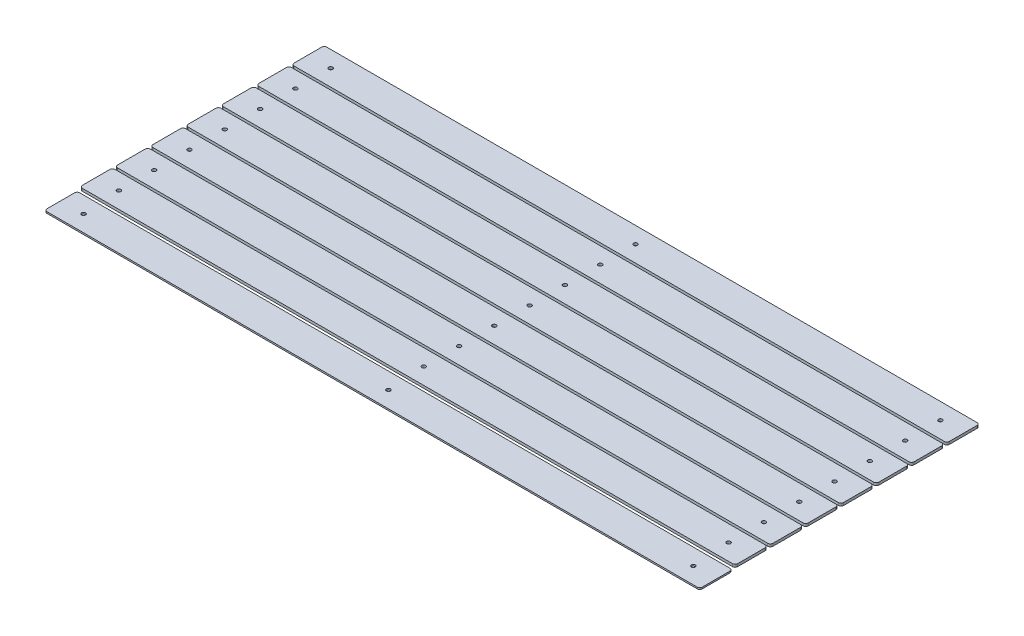
from build123d import *

# Parameters (mm, degrees)
SKETCH1_W             = 636.566333418
SKETCH1_H             = 31.75
BOSS_EXTRUDE1_DEPTH   = 1.524
SKETCH2_R             = 1.905
CUT_EXTRUDE1_DEPTH    = 2.524
FILLET1_R             = 2.54
SKETCH3_R             = 1.905
BOSS_EXTRUDE2_DEPTH   = 2.54
BOSS_EXTRUDE2_2_DEPTH = 2.54
BOSS_EXTRUDE2_3_DEPTH = 2.54
BOSS_EXTRUDE2_4_DEPTH = 2.54
BOSS_EXTRUDE2_5_DEPTH = 2.54
BOSS_EXTRUDE2_6_DEPTH = 2.54
BOSS_EXTRUDE2_7_DEPTH = 2.54


with BuildPart() as part:
    # Sketch1 → Boss-Extrude1 (new body)
    with BuildSketch(Plane(origin=(0, 0, 0), x_dir=(1, 0, 0), z_dir=(0, 1, 0))):
        Rectangle(SKETCH1_W, SKETCH1_H)
    extrude(amount=BOSS_EXTRUDE1_DEPTH)

    # Sketch2 → Cut-Extrude1 (cut, through all)
    with BuildSketch(Plane(origin=(0, 1.524, 0), x_dir=(1, 0, 0), z_dir=(0, 1, 0))):
        with Locations((-296.164, 0)):
            Circle(SKETCH2_R)
        with Locations((296.164, 0)):
            Circle(SKETCH2_R)
        Circle(SKETCH2_R)
    extrude(amount=-CUT_EXTRUDE1_DEPTH, mode=Mode.SUBTRACT)

    # Fillet1
    fillet1_edges = [part.edges().sort_by_distance(p)[0] for p in [
        (318.283166709, 0.762, 15.875),
        (-318.283166709, 0.762, 15.875),
        (-318.283166709, 0.762, -15.875),
        (318.283166709, 0.762, -15.875),
    ]]
    fillet(fillet1_edges, radius=FILLET1_R)


with BuildPart() as body_2:
    # Sketch3 → Boss-Extrude2 (new body)
    with BuildSketch(Plane(origin=(0, 1.524, 0), x_dir=(1, 0, 0), z_dir=(0, 1, 0))):
        with BuildLine():
            Line((-315.743166709, 18.415), (315.743166709, 18.415))
            ThreePointArc((315.743166709, 18.415), (317.539217933, 19.158948776), (318.283166709, 20.955))
            Line((318.283166709, 20.955), (318.283166709, 47.625))
            ThreePointArc((318.283166709, 47.625), (317.539217933, 49.421051224), (315.743166709, 50.165))
            Line((315.743166709, 50.165), (-315.743166709, 50.165))
            ThreePointArc((-315.743166709, 50.165), (-317.539217933, 49.421051224), (-318.283166709, 47.625))
            Line((-318.283166709, 47.625), (-318.283166709, 20.955))
            ThreePointArc((-318.283166709, 20.955), (-317.539217933, 19.158948776), (-315.743166709, 18.415))
        make_face()
        with Locations((296.164, 34.29)):
            Circle(SKETCH3_R, mode=Mode.SUBTRACT)
        with Locations((0, 34.29)):
            Circle(SKETCH3_R, mode=Mode.SUBTRACT)
        with Locations((-296.164, 34.29)):
            Circle(SKETCH3_R, mode=Mode.SUBTRACT)
    extrude(amount=BOSS_EXTRUDE2_DEPTH)


with BuildPart() as body_3:
    # Sketch3 → Boss-Extrude2 2 (new body)
    with BuildSketch(Plane(origin=(0, 1.524, 0), x_dir=(1, 0, 0), z_dir=(0, 1, 0))):
        with BuildLine():
            Line((-315.743166709, 52.705), (315.743166709, 52.705))
            ThreePointArc((315.743166709, 52.705), (317.539217933, 53.448948776), (318.283166709, 55.245))
            Line((318.283166709, 55.245), (318.283166709, 81.915))
            ThreePointArc((318.283166709, 81.915), (317.539217933, 83.711051224), (315.743166709, 84.455))
            Line((315.743166709, 84.455), (-315.743166709, 84.455))
            ThreePointArc((-315.743166709, 84.455), (-317.539217933, 83.711051224), (-318.283166709, 81.915))
            Line((-318.283166709, 81.915), (-318.283166709, 55.245))
            ThreePointArc((-318.283166709, 55.245), (-317.539217933, 53.448948776), (-315.743166709, 52.705))
        make_face()
        with Locations((296.164, 68.58)):
            Circle(SKETCH3_R, mode=Mode.SUBTRACT)
        with Locations((0, 68.58)):
            Circle(SKETCH3_R, mode=Mode.SUBTRACT)
        with Locations((-296.164, 68.58)):
            Circle(SKETCH3_R, mode=Mode.SUBTRACT)
    extrude(amount=BOSS_EXTRUDE2_2_DEPTH)


with BuildPart() as body_4:
    # Sketch3 → Boss-Extrude2 3 (new body)
    with BuildSketch(Plane(origin=(0, 1.524, 0), x_dir=(1, 0, 0), z_dir=(0, 1, 0))):
        with BuildLine():
            Line((-315.743166709, 86.995), (315.743166709, 86.995))
            ThreePointArc((315.743166709, 86.995), (317.539217933, 87.738948776), (318.283166709, 89.535))
            Line((318.283166709, 89.535), (318.283166709, 116.205))
            ThreePointArc((318.283166709, 116.205), (317.539217933, 118.001051224), (315.743166709, 118.745))
            Line((315.743166709, 118.745), (-315.743166709, 118.745))
            ThreePointArc((-315.743166709, 118.745), (-317.539217933, 118.001051224), (-318.283166709, 116.205))
            Line((-318.283166709, 116.205), (-318.283166709, 89.535))
            ThreePointArc((-318.283166709, 89.535), (-317.539217933, 87.738948776), (-315.743166709, 86.995))
        make_face()
        with Locations((296.164, 102.87)):
            Circle(SKETCH3_R, mode=Mode.SUBTRACT)
        with Locations((0, 102.87)):
            Circle(SKETCH3_R, mode=Mode.SUBTRACT)
        with Locations((-296.164, 102.87)):
            Circle(SKETCH3_R, mode=Mode.SUBTRACT)
    extrude(amount=BOSS_EXTRUDE2_3_DEPTH)


with BuildPart() as body_5:
    # Sketch3 → Boss-Extrude2 4 (new body)
    with BuildSketch(Plane(origin=(0, 1.524, 0), x_dir=(1, 0, 0), z_dir=(0, 1, 0))):
        with BuildLine():
            Line((-315.743166709, 121.285), (315.743166709, 121.285))
            ThreePointArc((315.743166709, 121.285), (317.539217933, 122.028948776), (318.283166709, 123.825))
            Line((318.283166709, 123.825), (318.283166709, 150.495))
            ThreePointArc((318.283166709, 150.495), (317.539217933, 152.291051224), (315.743166709, 153.035))
            Line((315.743166709, 153.035), (-315.743166709, 153.035))
            ThreePointArc((-315.743166709, 153.035), (-317.539217933, 152.291051224), (-318.283166709, 150.495))
            Line((-318.283166709, 150.495), (-318.283166709, 123.825))
            ThreePointArc((-318.283166709, 123.825), (-317.539217933, 122.028948776), (-315.743166709, 121.285))
        make_face()
        with Locations((296.164, 137.16)):
            Circle(SKETCH3_R, mode=Mode.SUBTRACT)
        with Locations((0, 137.16)):
            Circle(SKETCH3_R, mode=Mode.SUBTRACT)
        with Locations((-296.164, 137.16)):
            Circle(SKETCH3_R, mode=Mode.SUBTRACT)
    extrude(amount=BOSS_EXTRUDE2_4_DEPTH)


with BuildPart() as body_6:
    # Sketch3 → Boss-Extrude2 5 (new body)
    with BuildSketch(Plane(origin=(0, 1.524, 0), x_dir=(1, 0, 0), z_dir=(0, 1, 0))):
        with BuildLine():
            Line((-315.743166709, 155.575), (315.743166709, 155.575))
            ThreePointArc((315.743166709, 155.575), (317.539217933, 156.318948776), (318.283166709, 158.115))
            Line((318.283166709, 158.115), (318.283166709, 184.785))
            ThreePointArc((318.283166709, 184.785), (317.539217933, 186.581051224), (315.743166709, 187.325))
            Line((315.743166709, 187.325), (-315.743166709, 187.325))
            ThreePointArc((-315.743166709, 187.325), (-317.539217933, 186.581051224), (-318.283166709, 184.785))
            Line((-318.283166709, 184.785), (-318.283166709, 158.115))
            ThreePointArc((-318.283166709, 158.115), (-317.539217933, 156.318948776), (-315.743166709, 155.575))
        make_face()
        with Locations((296.164, 171.45)):
            Circle(SKETCH3_R, mode=Mode.SUBTRACT)
        with Locations((0, 171.45)):
            Circle(SKETCH3_R, mode=Mode.SUBTRACT)
        with Locations((-296.164, 171.45)):
            Circle(SKETCH3_R, mode=Mode.SUBTRACT)
    extrude(amount=BOSS_EXTRUDE2_5_DEPTH)


with BuildPart() as body_7:
    # Sketch3 → Boss-Extrude2 6 (new body)
    with BuildSketch(Plane(origin=(0, 1.524, 0), x_dir=(1, 0, 0), z_dir=(0, 1, 0))):
        with BuildLine():
            Line((-315.743166709, 189.865), (315.743166709, 189.865))
            ThreePointArc((315.743166709, 189.865), (317.539217933, 190.608948776), (318.283166709, 192.405))
            Line((318.283166709, 192.405), (318.283166709, 219.075))
            ThreePointArc((318.283166709, 219.075), (317.539217933, 220.871051224), (315.743166709, 221.615))
            Line((315.743166709, 221.615), (-315.743166709, 221.615))
            ThreePointArc((-315.743166709, 221.615), (-317.539217933, 220.871051224), (-318.283166709, 219.075))
            Line((-318.283166709, 219.075), (-318.283166709, 192.405))
            ThreePointArc((-318.283166709, 192.405), (-317.539217933, 190.608948776), (-315.743166709, 189.865))
        make_face()
        with Locations((296.164, 205.74)):
            Circle(SKETCH3_R, mode=Mode.SUBTRACT)
        with Locations((0, 205.74)):
            Circle(SKETCH3_R, mode=Mode.SUBTRACT)
        with Locations((-296.164, 205.74)):
            Circle(SKETCH3_R, mode=Mode.SUBTRACT)
    extrude(amount=BOSS_EXTRUDE2_6_DEPTH)


with BuildPart() as body_8:
    # Sketch3 → Boss-Extrude2 7 (new body)
    with BuildSketch(Plane(origin=(0, 1.524, 0), x_dir=(1, 0, 0), z_dir=(0, 1, 0))):
        with BuildLine():
            Line((-315.743166709, 224.155), (315.743166709, 224.155))
            ThreePointArc((315.743166709, 224.155), (317.539217933, 224.898948776), (318.283166709, 226.695))
            Line((318.283166709, 226.695), (318.283166709, 253.365))
            ThreePointArc((318.283166709, 253.365), (317.539217933, 255.161051224), (315.743166709, 255.905))
            Line((315.743166709, 255.905), (-315.743166709, 255.905))
            ThreePointArc((-315.743166709, 255.905), (-317.539217933, 255.161051224), (-318.283166709, 253.365))
            Line((-318.283166709, 253.365), (-318.283166709, 226.695))
            ThreePointArc((-318.283166709, 226.695), (-317.539217933, 224.898948776), (-315.743166709, 224.155))
        make_face()
        with Locations((296.164, 240.03)):
            Circle(SKETCH3_R, mode=Mode.SUBTRACT)
        with Locations((0, 240.03)):
            Circle(SKETCH3_R, mode=Mode.SUBTRACT)
        with Locations((-296.164, 240.03)):
            Circle(SKETCH3_R, mode=Mode.SUBTRACT)
    extrude(amount=BOSS_EXTRUDE2_7_DEPTH)


solid = Compound([part.part, body_2.part, body_3.part, body_4.part, body_5.part, body_6.part, body_7.part, body_8.part])
